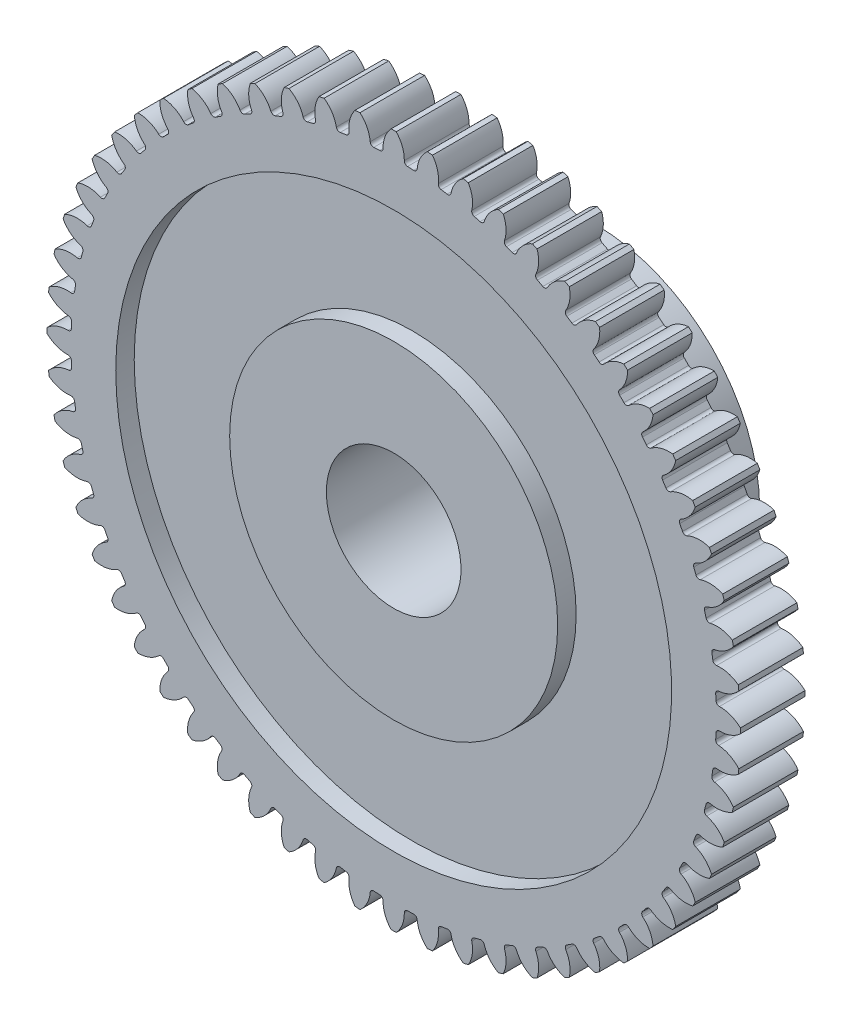
from build123d import *

# Parameters (mm, degrees)
CUT_EXTRUDE1_START = -10.525
CUT_EXTRUDE1_DEPTH = 11.525
CIRPATTERN1_COUNT  = 60


with BuildPart() as part:
    # Sketch3 → Revolve1 (revolve)
    with BuildSketch(Plane(origin=(0, 0, 0), x_dir=(0, 0, -1), z_dir=(1, 0, 0))):
        Polygon((-4.7625, 16.35125), (-1.7145, 16.35125), (-1.7145, 13.1064), (-2.585357143, 13.1064), (-2.585357143, 7.7343), (4.7625, 7.7343), (4.7625, 3.175), (-4.7625, 3.175), (-4.7625, 7.7343), (-3.891642857, 7.7343), (-3.891642857, 13.1064), (-4.7625, 13.1064), align=None)
    revolve(axis=Axis((0, 0, -4.7625), (0, 0, 1)))

    # Sketch4 → Cut-Extrude1 (cut)
    with BuildSketch(Plane.XY.offset(4.7625).offset(CUT_EXTRUDE1_START)):
        with BuildLine():
            ThreePointArc((-0.120558098, 16.350805555), (-0.406899024, 15.892846129), (-0.50067617, 15.360940303))
            ThreePointArc((-0.50067617, 15.360940303), (-0.5438027, 15.249337724), (-0.652591859, 15.199538608))
            ThreePointArc((-0.652591859, 15.199538608), (-0.796215251, 15.192692037), (-0.93976752, 15.18448837))
            ThreePointArc((-0.93976752, 15.18448837), (-1.053166146, 15.222643117), (-1.107722071, 15.329126375))
            ThreePointArc((-1.107722071, 15.329126375), (-1.256584794, 15.848315985), (-1.589226909, 16.273835884))
            ThreePointArc((-1.589226909, 16.273835884), (-0.855758305, 16.32884118), (-0.120558098, 16.350805555))
        make_face()
    cut_extrude1 = extrude(amount=CUT_EXTRUDE1_DEPTH, mode=Mode.SUBTRACT)

    # CirPattern1: Cut-Extrude1 ×60 about axis
    cirpattern1_axis = Axis((0, 0, 0), (0, 0, 1))
    for i in range(1, CIRPATTERN1_COUNT):
        add(cut_extrude1.rotate(cirpattern1_axis, i * 360 / CIRPATTERN1_COUNT), mode=Mode.SUBTRACT)


solid = part.part
